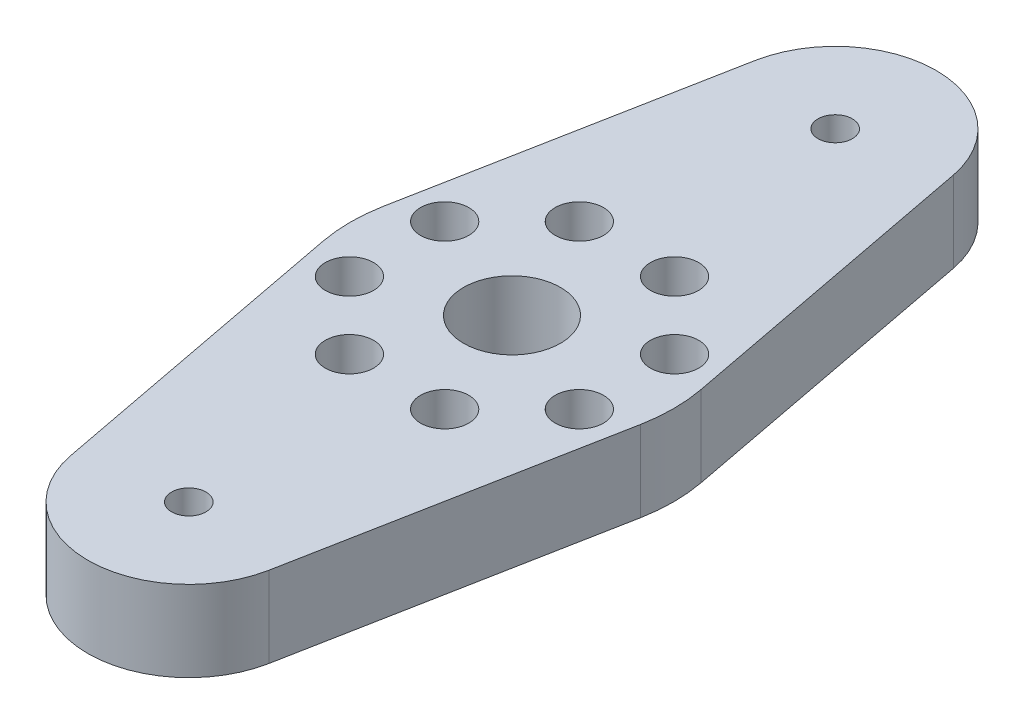
from build123d import *

# Parameters (mm, degrees)
SKETCH1_R                      = 3.81
BOSS_EXTRUDE1_DEPTH            = 6.35
F_6_32_TAPPED_HOLE1_D          = 2.7051
F_6_CLEARANCE_HOLE1_AT_2_COUNT = 2
F_6_CLEARANCE_HOLE1_AT_2_PITCH = 7.48452257
F_6_CLEARANCE_HOLE1_AT_3_COUNT = 2
F_6_CLEARANCE_HOLE1_AT_3_PITCH = 19.558
F_6_CLEARANCE_HOLE1_AT_4_COUNT = 2
F_6_CLEARANCE_HOLE1_AT_4_PITCH = 18.069235897
CIRPATTERN1_COUNT              = 2
CIRPATTERN1_ANGLE              = 90


with BuildPart() as part:
    # Sketch1 → Boss-Extrude1 (new body)
    with BuildSketch(Plane(origin=(0, 0, 0), x_dir=(1, 0, 0), z_dir=(0, 1, 0))):
        with BuildLine():
            Line((-12.474760456, 2.38125), (-7.796725285, 26.88828125))
            ThreePointArc((-7.796725285, 26.88828125), (0, 33.3375), (7.796725285, 26.88828125))
            Line((7.796725285, 26.88828125), (12.474760456, 2.38125))
            ThreePointArc((12.474760456, 2.38125), (12.7, 0), (12.474760456, -2.38125))
            Line((12.474760456, -2.38125), (7.796725285, -26.88828125))
            ThreePointArc((7.796725285, -26.88828125), (0, -33.3375), (-7.796725285, -26.88828125))
            Line((-7.796725285, -26.88828125), (-12.474760456, -2.38125))
            ThreePointArc((-12.474760456, -2.38125), (-12.7, 0), (-12.474760456, 2.38125))
        make_face()
        Circle(SKETCH1_R, mode=Mode.SUBTRACT)
    extrude(amount=BOSS_EXTRUDE1_DEPTH)

    # #6-32 Tapped Hole1 (through all)
    with Locations(Plane(origin=(0, 6.35, 0), x_dir=(1, 0, 0), z_dir=(0, 1, 0))):
        with Locations((0, -25.4), (0, 25.4)):
            Hole(F_6_32_TAPPED_HOLE1_D / 2)

    # Sketch6 → #6 Clearance Hole1 (revolve, cut)
    with BuildSketch(Plane(origin=(-3.742261285, 6.35, -9.034617948), x_dir=(0, 0, 1), z_dir=(1, 0, 0))):
        Polygon((0, 0), (0, 10.538824014), (1.89865, 9.398), (1.89865, 0), align=None)
    f_6_clearance_hole1 = revolve(axis=Axis((-3.742261285, 12.7, -9.034617948), (0, -1, 0)), mode=Mode.SUBTRACT)

    # #6 Clearance Hole1 at 2: #6 Clearance Hole1 ×2
    with Locations(*[(i * F_6_CLEARANCE_HOLE1_AT_2_PITCH, 0, 0) for i in range(1, F_6_CLEARANCE_HOLE1_AT_2_COUNT)]):
        add(f_6_clearance_hole1, mode=Mode.SUBTRACT)

    # #6 Clearance Hole1 at 3: #6 Clearance Hole1 ×2
    with Locations(*[Vector(0.382683432, 0, 0.923879533) * (i * F_6_CLEARANCE_HOLE1_AT_3_PITCH) for i in range(1, F_6_CLEARANCE_HOLE1_AT_3_COUNT)]):
        add(f_6_clearance_hole1, mode=Mode.SUBTRACT)

    # #6 Clearance Hole1 at 4: #6 Clearance Hole1 ×2
    with Locations(*[(0, 0, i * F_6_CLEARANCE_HOLE1_AT_4_PITCH) for i in range(1, F_6_CLEARANCE_HOLE1_AT_4_COUNT)]):
        add(f_6_clearance_hole1, mode=Mode.SUBTRACT)

    # CirPattern1: #6 Clearance Hole1 ×2 about axis
    cirpattern1_axis = Axis((0, 0, 0), (0, 1, 0))
    for i in range(1, CIRPATTERN1_COUNT):
        add(f_6_clearance_hole1.rotate(cirpattern1_axis, i * CIRPATTERN1_ANGLE / (CIRPATTERN1_COUNT - 1)), mode=Mode.SUBTRACT)

    # CirPattern1 copy 1 sketch → CirPattern1 copy 1 (revolve, cut)
    with BuildSketch(Plane(origin=(-9.034617948, 6.35, -3.742261285), x_dir=(1, 0, 0), z_dir=(0, 0, -1))):
        Polygon((0, 0), (0, 10.538824014), (1.89865, 9.398), (1.89865, 0), align=None)
    revolve(axis=Axis((-9.034617948, 12.7, -3.742261285), (0, -1, 0)), mode=Mode.SUBTRACT)

    # CirPattern1 copy 2 sketch → CirPattern1 copy 2 (revolve, cut)
    with BuildSketch(Plane(origin=(9.034617948, 6.35, -3.742261285), x_dir=(1, 0, 0), z_dir=(0, 0, -1))):
        Polygon((0, 0), (0, 10.538824014), (1.89865, 9.398), (1.89865, 0), align=None)
    revolve(axis=Axis((9.034617948, 12.7, -3.742261285), (0, -1, 0)), mode=Mode.SUBTRACT)

    # CirPattern1 copy 3 sketch → CirPattern1 copy 3 (revolve, cut)
    with BuildSketch(Plane(origin=(9.034617948, 6.35, 3.742261285), x_dir=(1, 0, 0), z_dir=(0, 0, -1))):
        Polygon((0, 0), (0, 10.538824014), (1.89865, 9.398), (1.89865, 0), align=None)
    revolve(axis=Axis((9.034617948, 12.7, 3.742261285), (0, -1, 0)), mode=Mode.SUBTRACT)


solid = part.part
